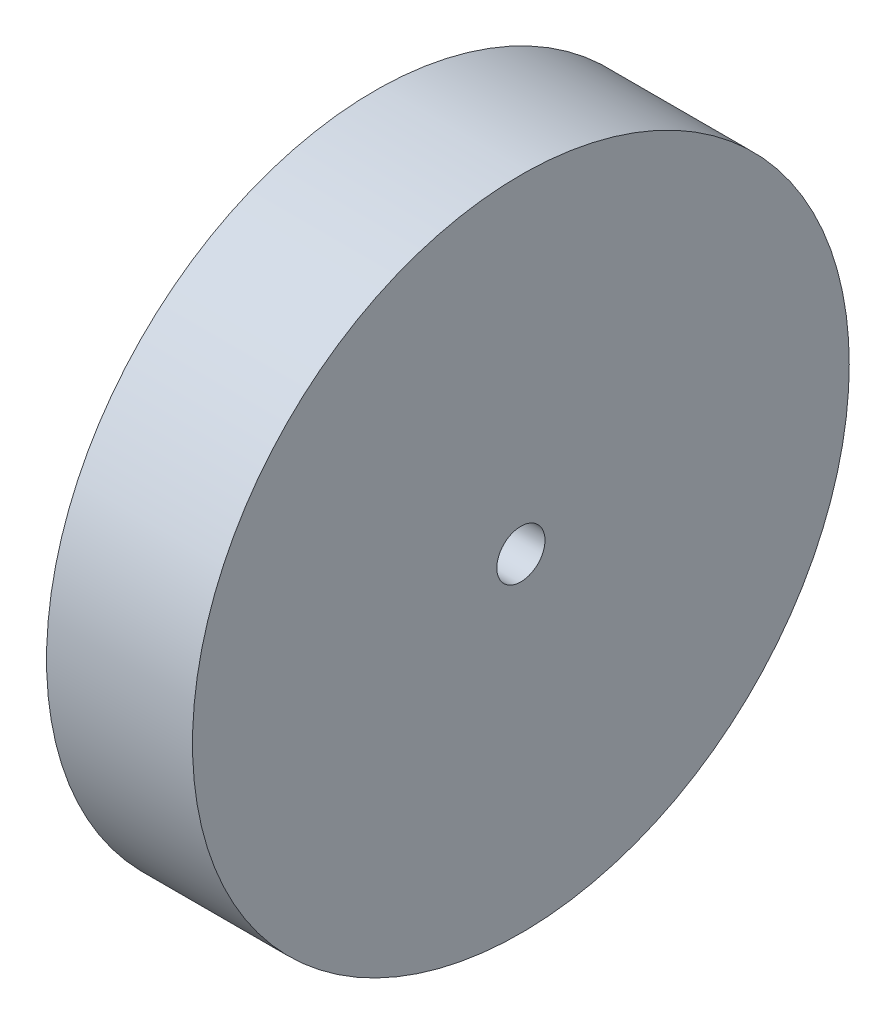
from build123d import *

# Parameters (mm, degrees)
SKETCH1_R           = 38.1
BOSS_EXTRUDE1_DEPTH = 16.933333333
SKETCH2_R           = 2.794
CUT_EXTRUDE1_DEPTH  = 16.933333333


with BuildPart() as part:
    # Sketch1 → Boss-Extrude1 (new body)
    with BuildSketch(Plane(origin=(0, 0, 0), x_dir=(0, 0, -1), z_dir=(1, 0, 0))):
        Circle(SKETCH1_R)
    extrude(amount=BOSS_EXTRUDE1_DEPTH)

    # Sketch2 → Cut-Extrude1 (cut)
    with BuildSketch(Plane(origin=(16.933333333, 0, 0), x_dir=(0, 0, -1), z_dir=(1, 0, 0))):
        Circle(SKETCH2_R)
    extrude(amount=-CUT_EXTRUDE1_DEPTH, mode=Mode.SUBTRACT)


solid = part.part
